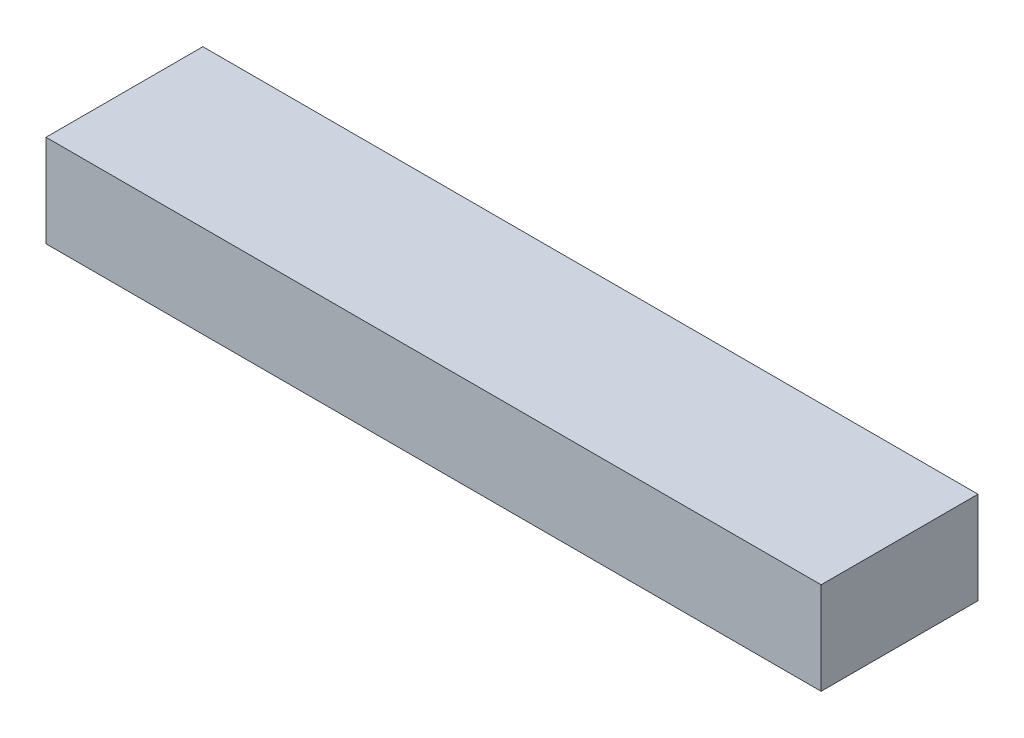
from build123d import *

# Parameters (mm, degrees)
BOSS_EXTRUDE1_DEPTH = 10
SKETCH2_R           = 1
CUT_EXTRUDE1_DEPTH  = 0.0001


with BuildPart() as part:
    # Sketch1 → Boss-Extrude1 (new body)
    with BuildSketch(Plane(origin=(0, 0, 0), x_dir=(1, 0, 0), z_dir=(0, 1, 0))):
        Polygon((-42, 0), (-42, 15), (42, 15), (42, 0), (42, -2), (-42, -2), align=None)
    extrude(amount=BOSS_EXTRUDE1_DEPTH)

    # Sketch2 → Cut-Extrude1 (cut)
    with BuildSketch(Plane(origin=(0, 0, 0), x_dir=(1, 0, 0), z_dir=(0, 1, 0))):
        Circle(SKETCH2_R)
    extrude(amount=CUT_EXTRUDE1_DEPTH, mode=Mode.SUBTRACT)


solid = part.part
